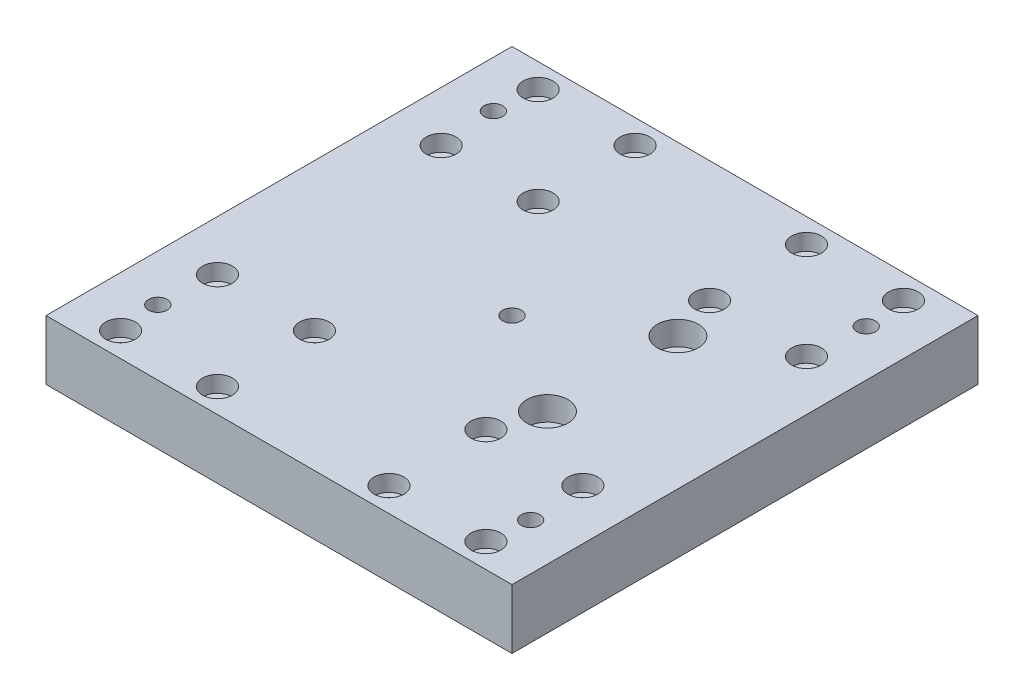
from build123d import *

# Parameters (mm, degrees)
SKETCH1_W                                           = 125
SKETCH1_H                                           = 125
EXTRUDE1_DEPTH                                      = 16
CBORE_FOR_M4_HEX_SOCKET_HEAD_CAP_SCREW1_D           = 4.5
CBORE_FOR_M4_HEX_SOCKET_HEAD_CAP_SCREW1_CBORE_D     = 8
CBORE_FOR_M4_HEX_SOCKET_HEAD_CAP_SCREW1_CBORE_DEPTH = 4.4
CBORE_FOR_M6_HEX_SOCKET_HEAD_CAP_SCREW1_D           = 6.6
CBORE_FOR_M6_HEX_SOCKET_HEAD_CAP_SCREW1_CBORE_D     = 11
CBORE_FOR_M6_HEX_SOCKET_HEAD_CAP_SCREW1_CBORE_DEPTH = 6.4
M6_TAPPED_HOLE1_D                                   = 5
M4_TAPPED_HOLE1_D                                   = 3.3
M4_TAPPED_HOLE1_DEPTH                               = 11.5
M4_TAPPED_HOLE1_TIP                                 = 0.991420021


with BuildPart() as part:
    # Sketch1 → Extrude1 (new body)
    with BuildSketch(Plane(origin=(0, 0, 0), x_dir=(1, 0, 0), z_dir=(0, 1, 0))):
        Rectangle(SKETCH1_W, SKETCH1_H)
    extrude(amount=EXTRUDE1_DEPTH)

    # CBORE for M4 Hex Socket Head Cap Screw1 (through all)
    with Locations(Plane(origin=(0, 16, 0), x_dir=(1, 0, 0), z_dir=(0, 1, 0))):
        with Locations((-49, 56), (-23, 56), (-49, 30), (-23, 30), (23, 30), (49, 30), (23, 56), (49, 56), (49, -56), (23, -56), (49, -30), (23, -30), (-23, -56), (-23, -30), (-49, -30), (-49, -56)):
            CounterBoreHole(CBORE_FOR_M4_HEX_SOCKET_HEAD_CAP_SCREW1_D / 2, CBORE_FOR_M4_HEX_SOCKET_HEAD_CAP_SCREW1_CBORE_D / 2, CBORE_FOR_M4_HEX_SOCKET_HEAD_CAP_SCREW1_CBORE_DEPTH)

    # CBORE for M6 Hex Socket Head Cap Screw1 (through all)
    with Locations(Plane(origin=(0, 16, 0), x_dir=(1, 0, 0), z_dir=(0, 1, 0))):
        with Locations((27, 17.5), (27, -17.5)):
            CounterBoreHole(CBORE_FOR_M6_HEX_SOCKET_HEAD_CAP_SCREW1_D / 2, CBORE_FOR_M6_HEX_SOCKET_HEAD_CAP_SCREW1_CBORE_D / 2, CBORE_FOR_M6_HEX_SOCKET_HEAD_CAP_SCREW1_CBORE_DEPTH)

    # M6 Tapped Hole1 (through all)
    with Locations(Plane(origin=(0, 16, 0), x_dir=(1, 0, 0), z_dir=(0, 1, 0))):
        with Locations((-50, 45), (50, 45), (50, -45), (-50, -45), (0, 0)):
            Hole(M6_TAPPED_HOLE1_D / 2)

    # M4 Tapped Hole1
    with Locations(Plane(origin=(0, 0, -62.5), x_dir=(-1, 0, 0), z_dir=(0, 0, -1))):
        with Locations((36, 7.5), (24, 7.5)):
            Hole(M4_TAPPED_HOLE1_D / 2, depth=M4_TAPPED_HOLE1_DEPTH)
            with Locations((0, 0, -(M4_TAPPED_HOLE1_DEPTH + M4_TAPPED_HOLE1_TIP / 2))):  # 118° drill point
                Cone(0, M4_TAPPED_HOLE1_D / 2, M4_TAPPED_HOLE1_TIP, mode=Mode.SUBTRACT)


solid = part.part
